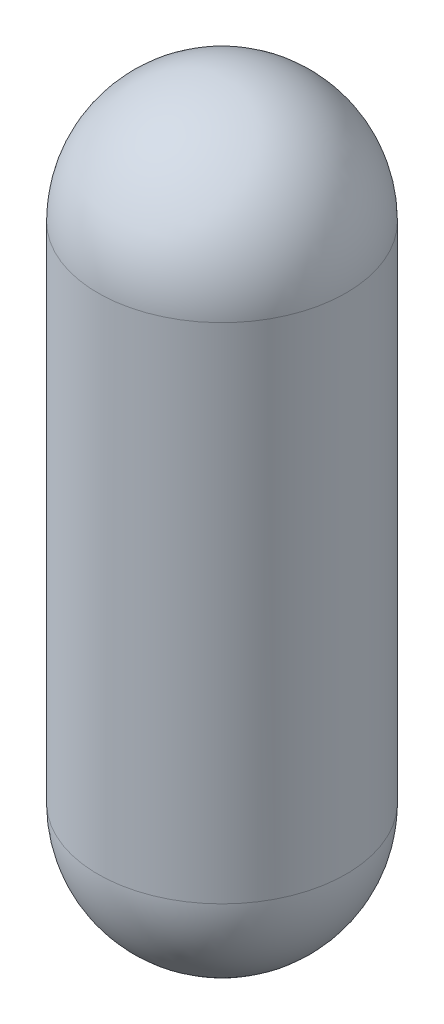
from build123d import *


with BuildPart() as part:
    # Sketch1 → Revolve1 (revolve)
    with BuildSketch(Plane.XY):
        with BuildLine():
            Line((0, 1667.26), (0, 1669.8))
            ThreePointArc((0, 1669.8), (233.486659148, 1573.086659148), (330.2, 1339.6))
            Line((330.2, 1339.6), (330.2, 0))
            ThreePointArc((330.2, 0), (233.486659148, -233.486659148), (0, -330.2))
            Line((0, -330.2), (0, -327.66))
            ThreePointArc((0, -327.66), (231.690607924, -231.690607924), (327.66, 0))
            Line((327.66, 0), (327.66, 1339.6))
            ThreePointArc((327.66, 1339.6), (231.690607924, 1571.290607924), (0, 1667.26))
        make_face()
    revolve(axis=Axis((0, 0, 0), (0, 1, 0)))


solid = part.part
